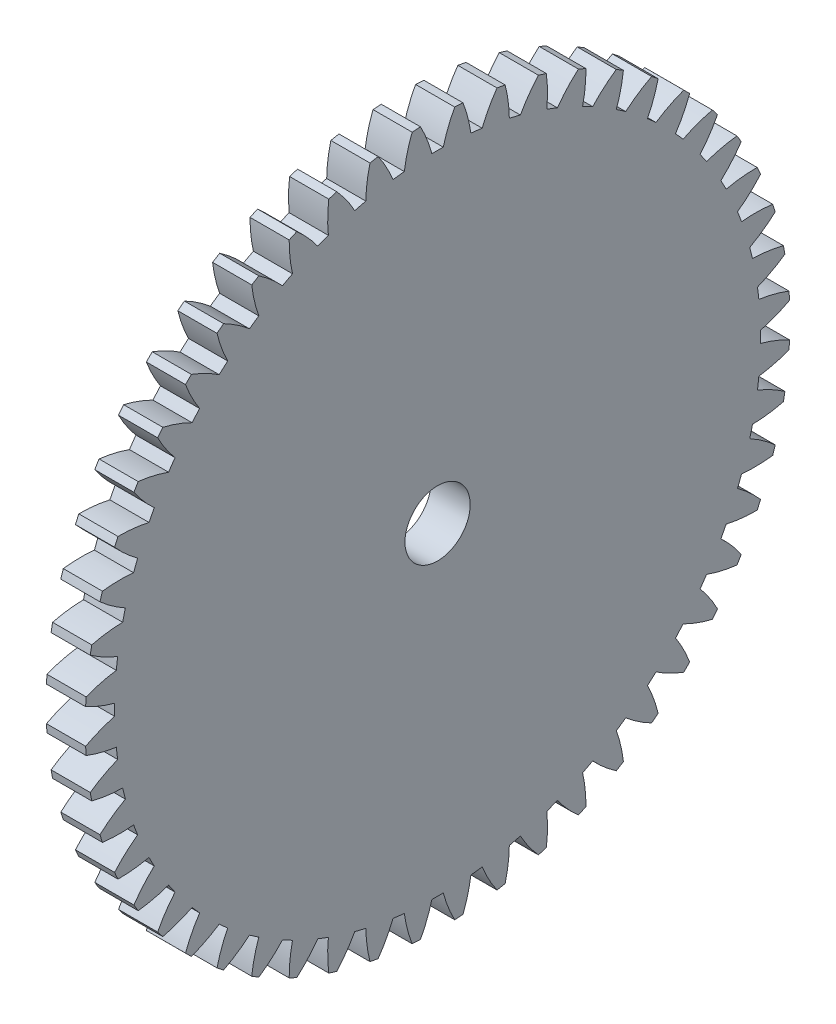
from build123d import *

# Parameters (mm, degrees)
BASPROSKE_W     = 3
BASPROSKE_H     = 27
TOOTHCUT_DEPTH  = 39.301436004
TEETHCUTS_COUNT = 52
TEETHCUTS_ANGLE = 353.076923077
BORSKE_R        = 2.5
BORE_DEPTH      = 50.0000508


with BuildPart() as part:
    # BasProSke → Base-Revolve (revolve)
    with BuildSketch(Plane(origin=(0, 0, 0), x_dir=(1, 0, 0), z_dir=(0, 1, 0)), mode=Mode.PRIVATE) as base_revolve_sk:
        with Locations((1.5, 13.5)):
            Rectangle(BASPROSKE_W, BASPROSKE_H)
    revolve(base_revolve_sk.sketch.rotate(Axis((-10, 0, 0), (1, 0, 0)), 180), axis=Axis((-10, 0, 0), (1, 0, 0)))

    # TooCutSke → ToothCut (cut, through all)
    with BuildSketch(Plane(origin=(0, 0, 0), x_dir=(0, 0, -1), z_dir=(1, 0, 0))):
        with BuildLine():
            ThreePointArc((0.435942585, 24.745160235), (0, 24.749), (-0.435942585, 24.745160235))
            ThreePointArc((-0.435942585, 24.745160235), (-0.815222213, 25.894951619), (-1.325559521, 26.992871969))
            ThreePointArc((-1.325559521, 26.992871969), (0, 27.0254), (1.325559521, 26.992871969))
            ThreePointArc((1.325559521, 26.992871969), (0.815222213, 25.894951619), (0.435942585, 24.745160235))
        make_face()
    toothcut = extrude(amount=TOOTHCUT_DEPTH, mode=Mode.SUBTRACT)

    # TeethCuts: ToothCut ×52 about axis
    teethcuts_axis = Axis((-10, 0, 0), (1, 0, 0))
    for i in range(1, TEETHCUTS_COUNT):
        add(toothcut.rotate(teethcuts_axis, i * TEETHCUTS_ANGLE / (TEETHCUTS_COUNT - 1)), mode=Mode.SUBTRACT)

    # BorSke → Bore (cut, symmetric)
    with BuildSketch(Plane(origin=(0, 0, 0), x_dir=(0, 0, -1), z_dir=(1, 0, 0))):
        with Locations(Location((0, 0, 0), (0, 0, 180))):
            Circle(BORSKE_R)
    extrude(amount=BORE_DEPTH, both=True, mode=Mode.SUBTRACT)


solid = part.part
